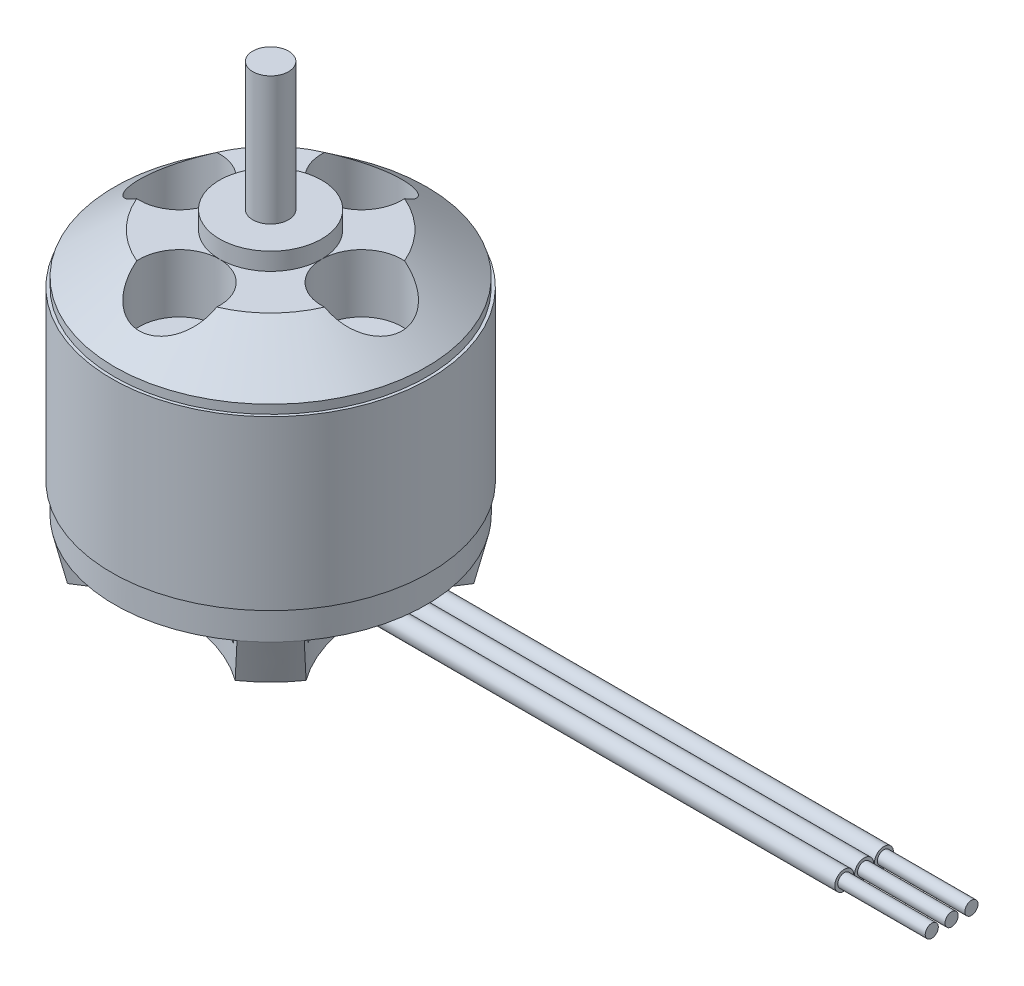
from build123d import *

# Parameters (mm, degrees)
SKETCH2_R                       = 3.4925
CUT_EXTRUDE1_DEPTH              = 5.08
SKETCH3_R                       = 12.460238567
CUT_EXTRUDE2_DEPTH              = 3.6576
SKETCH4_R                       = 12.1158
CUT_EXTRUDE3_DEPTH              = 1.27
CUT_EXTRUDE3_DEPTH_BACK         = 2.54
F_4_40_TAPPED_HOLE1_D           = 2.2606
F_4_40_TAPPED_HOLE1_DEPTH       = 2.54
F_4_40_TAPPED_HOLE1_CSINK_D     = 3.048
F_4_40_TAPPED_HOLE1_CSINK_ANGLE = 90
F_4_40_TAPPED_HOLE1_TIP         = 0.679152758
SKETCH10_R                      = 0.8255
SKETCH13_R                      = 0.5715
BOSS_EXTRUDE1_DEPTH             = 7.62


with BuildPart() as part:
    # Sketch1 → Revolve1 (revolve)
    with BuildSketch(Plane.XY):
        Polygon((0, 11.176), (1.55575, 11.176), (1.55575, 0), (4.445, 0), (4.445, -1.524), (8.89, -1.524), (13.589, -5.08), (13.589, -5.842), (13.843, -5.842), (13.843, -20.4724), (13.589, -20.4724), (13.589, -23.0124), (12.7, -26.67), (3.81, -26.67), (3.81, -26.924), (1.55575, -26.924), (1.55575, -28.956), (0, -28.956), align=None)
    revolve(axis=Axis((0, -28.956, 0), (0, 1, 0)))

    # Sketch2 → Cut-Extrude1 (cut)
    with BuildSketch(Plane(origin=(0, -1.524, 0), x_dir=(1, 0, 0), z_dir=(0, 1, 0))):
        with Locations((0, 7.9375)):
            Circle(SKETCH2_R)
        with Locations((7.9375, 0)):
            Circle(SKETCH2_R)
        with Locations((0, -7.9375)):
            Circle(SKETCH2_R)
        with Locations((-7.9375, 0)):
            Circle(SKETCH2_R)
    extrude(amount=-CUT_EXTRUDE1_DEPTH, mode=Mode.SUBTRACT)

    # Sketch3 → Cut-Extrude2 (cut)
    with BuildSketch(Plane.XZ.offset(26.67)):
        with Locations((0, 20.486638567)):
            Circle(SKETCH3_R)
        with Locations((-20.486638567, 0)):
            Circle(SKETCH3_R)
        with Locations((0, -20.486638567)):
            Circle(SKETCH3_R)
        with Locations((20.486638567, 0)):
            Circle(SKETCH3_R)
    extrude(amount=-CUT_EXTRUDE2_DEPTH, mode=Mode.SUBTRACT)

    # Sketch4 → Cut-Extrude3 (cut, two sides)
    with BuildSketch(Plane.XZ.offset(23.0124)) as cut_extrude3_sk:
        Circle(SKETCH4_R)
    extrude(amount=CUT_EXTRUDE3_DEPTH, mode=Mode.SUBTRACT)
    extrude(cut_extrude3_sk.sketch, amount=-CUT_EXTRUDE3_DEPTH_BACK, mode=Mode.SUBTRACT)

    # #4-40 Tapped Hole1
    with Locations(Plane(origin=(0, -26.67, 0), x_dir=(-1, 0, 0), z_dir=(0, -1, 0))):
        with Locations((5.666541612, -5.666541612), (-6.672330298, -6.672330298), (-5.666541612, 5.666541612), (6.672330298, 6.672330298)):
            CounterSinkHole(F_4_40_TAPPED_HOLE1_D / 2, F_4_40_TAPPED_HOLE1_CSINK_D / 2, depth=F_4_40_TAPPED_HOLE1_DEPTH, counter_sink_angle=F_4_40_TAPPED_HOLE1_CSINK_ANGLE)
            with Locations((0, 0, -(F_4_40_TAPPED_HOLE1_DEPTH + F_4_40_TAPPED_HOLE1_TIP / 2))):  # 118° drill point
                Cone(0, F_4_40_TAPPED_HOLE1_D / 2, F_4_40_TAPPED_HOLE1_TIP, mode=Mode.SUBTRACT)


with BuildPart() as body_2:
    # Sweep1: sweep along a path in Sketch12
    with BuildLine(Plane.XY) as sweep1_path:
        Line((0, -21.2979), (3.81, -21.2979))
        ThreePointArc((3.81, -21.2979), (5.388147914, -21.635637579), (6.689842062, -22.589686769))
        ThreePointArc((6.689842062, -22.589686769), (7.991536209, -23.543735959), (9.569684124, -23.881473538))
        Line((9.569684124, -23.881473538), (51.689, -23.881473538))
    # Sketch10 → Sweep1 (sweep)
    with BuildSketch(Plane(origin=(0, 0, 0), x_dir=(0, 0, -1), z_dir=(1, 0, 0))):
        with Locations((0, -21.2979)):
            Circle(SKETCH10_R)
        with Locations((-1.7272, -21.2979)):
            Circle(SKETCH10_R)
        with Locations((1.7272, -21.2979)):
            Circle(SKETCH10_R)
    sweep(path=sweep1_path.line)

    # Sketch13 → Boss-Extrude1 (add)
    with BuildSketch(Plane(origin=(51.689, 0, 0), x_dir=(0, 0, -1), z_dir=(1, 0, 0))):
        with Locations((1.7272, -23.881473538)):
            Circle(SKETCH13_R)
        with Locations((0, -23.881473538)):
            Circle(SKETCH13_R)
        with Locations((-1.7272, -23.881473538)):
            Circle(SKETCH13_R)
    extrude(amount=BOSS_EXTRUDE1_DEPTH)


solid = Compound([part.part, body_2.part])
